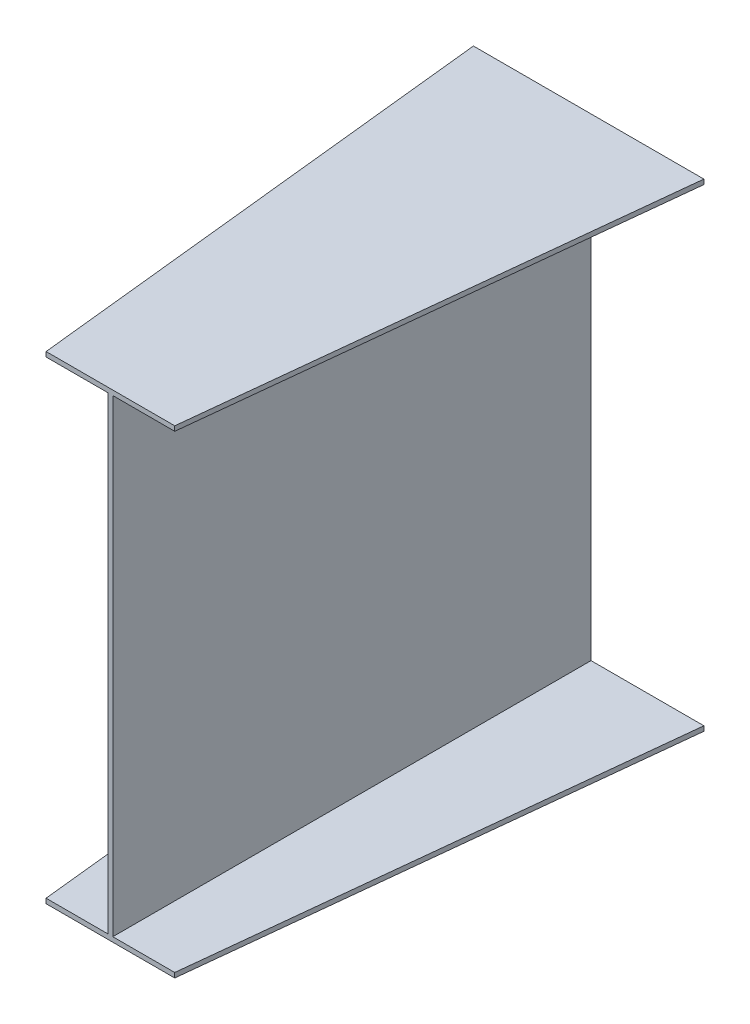
from build123d import *


with BuildPart() as part:
    # Sketch1 → Loft3 section 0
    with BuildSketch(Plane.XY):
        Polygon((-236, -10), (246, -10), (246, 0), (10, 0), (10, 980), (246, 980), (246, 990), (-236, 990), (-236, 980), (0, 980), (0, 0), (-236, 0), align=None)
    # Sketch3 → Loft3 section 1
    with BuildSketch(Plane.XY.offset(1000)):
        Polygon((-129.5, 990), (139.5, 990), (139.5, 980), (10, 980), (10, 0), (139.5, 0), (139.5, -10), (-129.5, -10), (-129.5, 0), (0, 0), (0, 980), (-129.5, 980), align=None)
    loft()


solid = part.part
